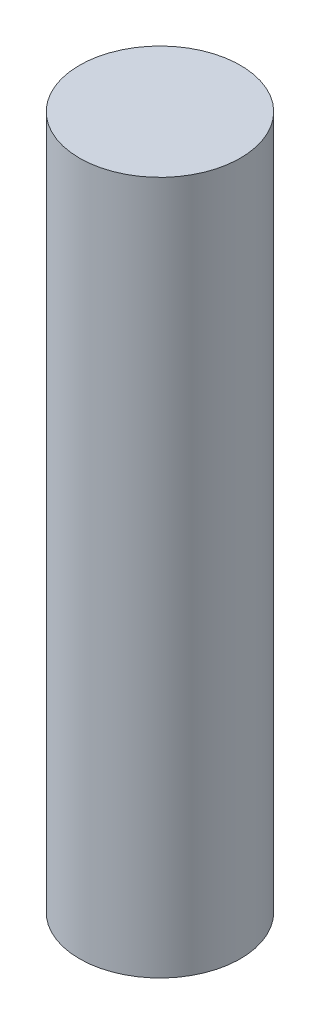
from build123d import *

# Parameters (mm, degrees)
SKETCH1_R           = 10
BOSS_EXTRUDE1_DEPTH = 86.19


with BuildPart() as part:
    # Sketch1 → Boss-Extrude1 (new body)
    with BuildSketch(Plane(origin=(0, 0, 0), x_dir=(1, 0, 0), z_dir=(0, 1, 0))):
        Circle(SKETCH1_R)
    extrude(amount=BOSS_EXTRUDE1_DEPTH)


solid = part.part
